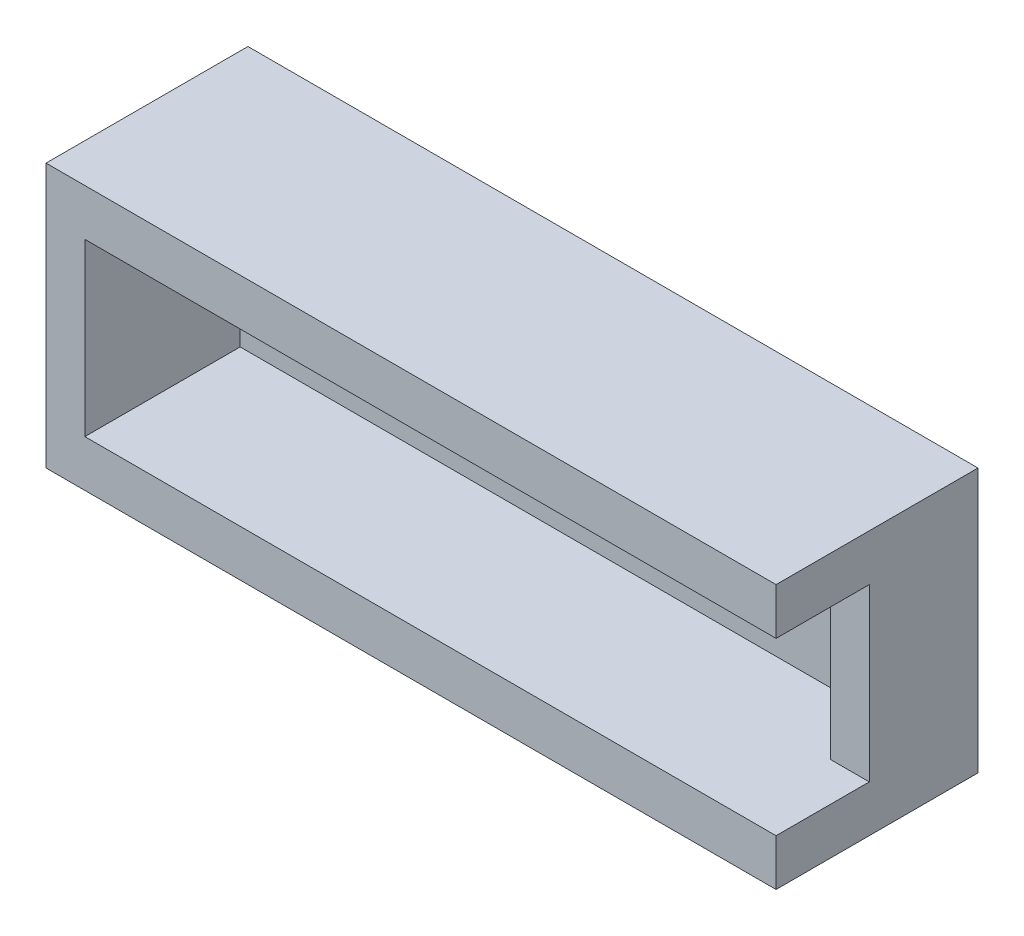
from build123d import *

# Parameters (mm, degrees)
SKETCH_1_W          = 47
SKETCH_1_H          = 17
SKETCH_1_W_2        = 42
SKETCH_1_H_2        = 11
EXTRUDE_1_DEPTH     = 10
SKETCH_2_W          = 47
SKETCH_2_H          = 17
EXTRUDE_2_DEPTH     = 3
SKETCH_3_W          = 6
SKETCH_3_H          = 11
CUT_EXTRUDE_2_DEPTH = 3


with BuildPart() as part:
    # 草圖1 → 填料-伸長1 (new body)
    with BuildSketch(Plane.XY):
        with Locations((8.49357684, 1.797560976)):
            Rectangle(SKETCH_1_W, SKETCH_1_H)
        with Locations((8.49357684, 1.797560976)):
            Rectangle(SKETCH_1_W_2, SKETCH_1_H_2, mode=Mode.SUBTRACT)
    extrude(amount=EXTRUDE_1_DEPTH)

    # 草圖2 → 填料-伸長2 (add)
    with BuildSketch(Plane(origin=(0, 0, 0), x_dir=(-1, 0, 0), z_dir=(0, 0, -1))):
        with Locations((-8.49357684, 1.797560976)):
            Rectangle(SKETCH_2_W, SKETCH_2_H)
    extrude(amount=EXTRUDE_2_DEPTH)

    # 草圖3 → 除料-伸長2 (cut)
    with BuildSketch(Plane(origin=(31.99357684, 0, 0), x_dir=(0, 0, -1), z_dir=(1, 0, 0))):
        with Locations((-7, 1.797560976)):
            Rectangle(SKETCH_3_W, SKETCH_3_H)
    extrude(amount=-CUT_EXTRUDE_2_DEPTH, mode=Mode.SUBTRACT)


solid = part.part
